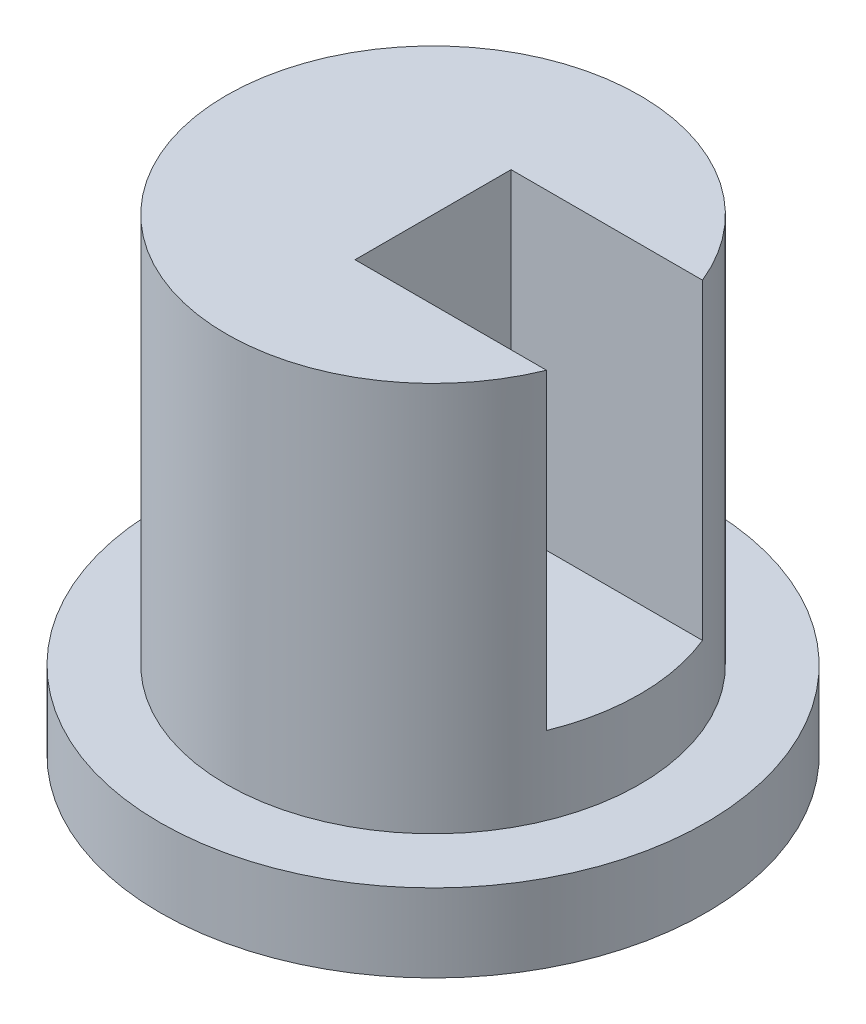
from build123d import *

# Parameters (mm, degrees)
CROQUIS1_R              = 35
SALIENTE_EXTRUIR1_DEPTH = 10
CROQUIS2_R              = 26.5
SALIENTE_EXTRUIR3_DEPTH = 50
CROQUIS4_W              = 20
CROQUIS4_H              = 40
CORTAR_EXTRUIR2_DEPTH   = 40


with BuildPart() as part:
    # Croquis1 → Saliente-Extruir1 (new body)
    with BuildSketch(Plane(origin=(0, 0, 0), x_dir=(1, 0, 0), z_dir=(0, 1, 0))):
        Circle(CROQUIS1_R)
    extrude(amount=SALIENTE_EXTRUIR1_DEPTH)

    # Croquis2 → Saliente-Extruir3 (add)
    with BuildSketch(Plane(origin=(0, 10, 0), x_dir=(1, 0, 0), z_dir=(0, 1, 0))):
        Circle(CROQUIS2_R)
    extrude(amount=SALIENTE_EXTRUIR3_DEPTH)

    # Croquis4 → Cortar-Extruir2 (cut)
    with BuildSketch(Plane(origin=(0, 0, 0), x_dir=(0, 0, -1), z_dir=(1, 0, 0))):
        with Locations((0, 40)):
            Rectangle(CROQUIS4_W, CROQUIS4_H)
    extrude(amount=CORTAR_EXTRUIR2_DEPTH, mode=Mode.SUBTRACT)


solid = part.part
